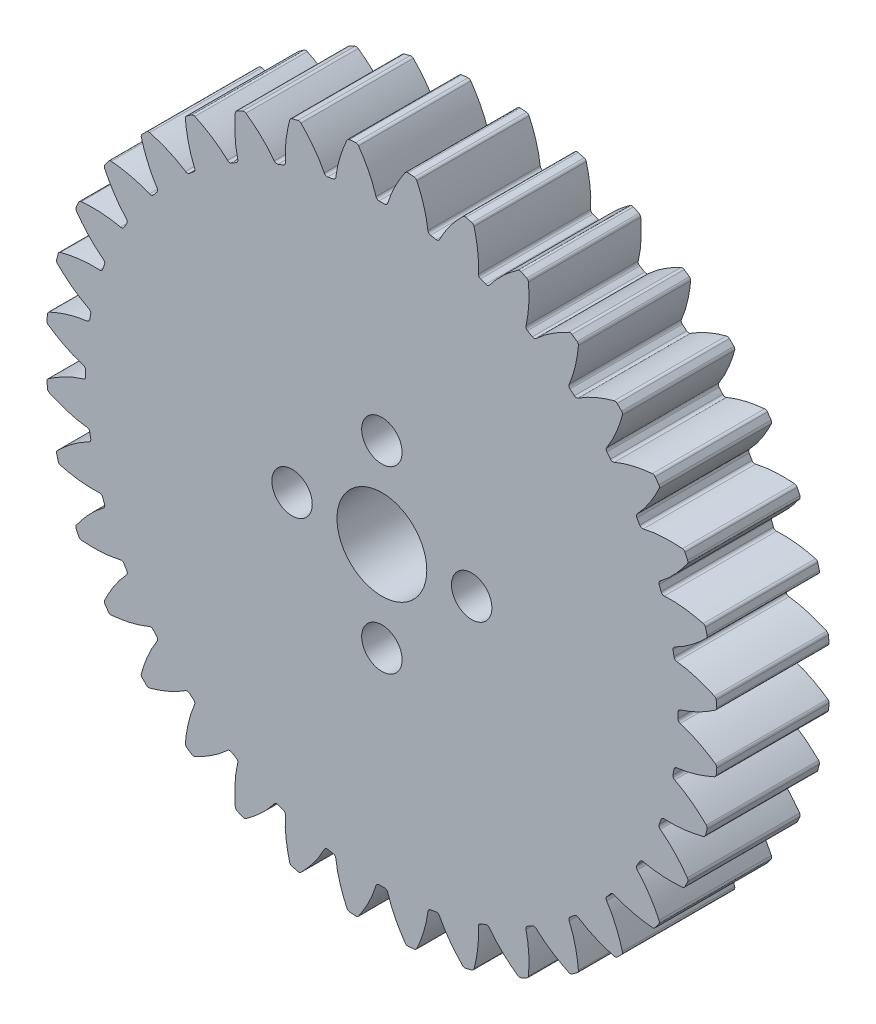
from build123d import *

# Parameters (mm, degrees)
SKETCH1_R                                = 19
BOSS_EXTRUDE1_DEPTH                      = 6.35
CUT_EXTRUDE_DCGTBC_DEPTH                 = 7.35
FILLET_TIP_DCGTBC_R                      = 0.177827283
CIRPATTERN_DCGTBC_COUNT                  = 36
FILLET_TIP_DCGTBC_OF_CIRPATTERN_DCGTBC_R = 0.177827283
SKETCH4_R                                = 2.54
CUT_EXTRUDE2_DEPTH                       = 7.3500001
SKETCH5_R                                = 1.143
CUT_EXTRUDE7_DEPTH                       = 12.7


with BuildPart() as part:
    # Sketch1 → Boss-Extrude1 (new body)
    with BuildSketch(Plane.XY):
        Circle(SKETCH1_R)
    extrude(amount=BOSS_EXTRUDE1_DEPTH)

    # DCGTBC → Cut-Extrude-DCGTBC (cut, through all)
    with BuildSketch(Plane.XY):
        with BuildLine():
            add(Edge.make_bspline(
                [(0.29704595, 16.747365874), (0.298715281, 16.754000326), (0.305790422, 16.781837292), (0.318741059, 16.830755481), (0.338462236, 16.900540736), (0.363884311, 16.984252564), (0.396683632, 17.085360101), (0.438797846, 17.206173577), (0.492066502, 17.346707309), (0.557243274, 17.505246447), (0.628738854, 17.665836752), (0.703249343, 17.823018377), (0.783288406, 17.980785462), (0.864099114, 18.13268838), (0.95287532, 18.289306313), (1.037284199, 18.433287332), (1.137172939, 18.593224042), (1.219340619, 18.721900199), (1.308631383, 18.853618864), (1.352739478, 18.917546944), (1.375554666, 18.950141144)],
                knots=[0.138286232, 0.138286232, 0.138286232, 0.138286232, 0.138286232, 0.146842496, 0.174208854, 0.201574956, 0.228941013, 0.256307345, 0.307035032, 0.361767352, 0.416499661, 0.471231937, 0.525964282, 0.580696616, 0.635428982, 0.690161387, 0.744893688, 0.799626082, 0.854358407, 0.909090915, 0.909090915, 0.909090915, 0.909090915, 0.909090915], degree=4))
            ThreePointArc((1.375554666, 18.950141144), (0, 19), (-1.375554666, 18.950141144))
            add(Edge.make_bspline(
                [(-0.29704595, 16.747365874), (-0.298715281, 16.754000326), (-0.305790422, 16.781837292), (-0.318741059, 16.830755481), (-0.338462236, 16.900540736), (-0.363884311, 16.984252564), (-0.396683632, 17.085360101), (-0.438797846, 17.206173577), (-0.492066502, 17.346707309), (-0.557243274, 17.505246447), (-0.628738854, 17.665836752), (-0.703249343, 17.823018377), (-0.783288406, 17.980785462), (-0.864099114, 18.13268838), (-0.95287532, 18.289306313), (-1.037284199, 18.433287332), (-1.137172939, 18.593224042), (-1.219340619, 18.721900199), (-1.308631383, 18.853618864), (-1.352739478, 18.917546944), (-1.375554666, 18.950141144)],
                knots=[0.138286232, 0.138286232, 0.138286232, 0.138286232, 0.138286232, 0.146842496, 0.174208854, 0.201574956, 0.228941013, 0.256307345, 0.307035032, 0.361767352, 0.416499661, 0.471231937, 0.525964282, 0.580696616, 0.635428982, 0.690161387, 0.744893688, 0.799626082, 0.854358407, 0.909090915, 0.909090915, 0.909090915, 0.909090915, 0.909090915], degree=4))
            ThreePointArc((-0.29704595, 16.747365874), (0, 16.75), (0.29704595, 16.747365874))
        make_face()
    cut_extrude_dcgtbc = extrude(amount=CUT_EXTRUDE_DCGTBC_DEPTH, mode=Mode.SUBTRACT)

    # Fillet-Tip-DCGTBC
    fillet_tip_dcgtbc_edges = [part.edges().sort_by_distance(p)[0] for p in [
        (1.375554666, 18.950141144, 3.175),
        (-1.375554666, 18.950141144, 3.175),
        (0.29704595, 16.747365874, 3.175),
        (-0.29704595, 16.747365874, 3.175),
    ]]
    fillet(fillet_tip_dcgtbc_edges, radius=FILLET_TIP_DCGTBC_R)

    # CirPattern-DCGTBC: Cut-Extrude-DCGTBC ×36 about axis
    cirpattern_dcgtbc_axis = Axis((0, 0, 6.35), (0, 0, 1))
    for i in range(1, CIRPATTERN_DCGTBC_COUNT):
        add(cut_extrude_dcgtbc.rotate(cirpattern_dcgtbc_axis, i * 360 / CIRPATTERN_DCGTBC_COUNT), mode=Mode.SUBTRACT)

    # Fillet-Tip-DCGTBC of CirPattern-DCGTBC
    fillet_tip_dcgtbc_of_cirpattern_dcgtbc_edges = [part.edges().sort_by_distance(p)[0] for p in [
        (-1.936000577, 18.90110848, 3.175),
        (-4.645314376, 18.423383358, 3.175),
        (-2.61561641, 16.544517243, 3.175),
        (-3.20068272, 16.441354267, 3.175),
        (-5.188731421, 18.277775199, 3.175),
        (-7.773928559, 17.336840391, 3.175),
        (-5.448804589, 15.838971828, 3.175),
        (-6.007068364, 15.63578043, 3.175),
        (-8.283805287, 17.099080969, 3.175),
        (-10.666335857, 15.723526303, 3.175),
        (-8.116433598, 14.652167268, 3.175),
        (-8.630932276, 14.355121318, 3.175),
        (-11.127179921, 15.400839815, 3.175),
        (-13.234651937, 13.632460824, 3.175),
        (-10.537448879, 13.020164021, 3.175),
        (-10.992549678, 12.638289108, 3.175),
        (-13.632460824, 13.234651937, 3.175),
        (-15.400839815, 11.127179921, 3.175),
        (-12.638289108, 10.992549678, 3.175),
        (-13.020164021, 10.537448879, 3.175),
        (-15.723526303, 10.666335857, 3.175),
        (-17.099080969, 8.283805287, 3.175),
        (-14.355121318, 8.630932276, 3.175),
        (-14.652167268, 8.116433598, 3.175),
        (-17.336840391, 7.773928559, 3.175),
        (-18.277775199, 5.188731421, 3.175),
        (-15.63578043, 6.007068364, 3.175),
        (-15.838971828, 5.448804589, 3.175),
        (-18.423383358, 4.645314376, 3.175),
        (-18.90110848, 1.936000577, 3.175),
        (-16.441354267, 3.20068272, 3.175),
        (-16.544517243, 2.61561641, 3.175),
        (-18.950141144, 1.375554666, 3.175),
        (-18.950141144, -1.375554666, 3.175),
        (-16.747365874, 0.29704595, 3.175),
        (-16.747365874, -0.29704595, 3.175),
        (-18.90110848, -1.936000577, 3.175),
        (-18.423383358, -4.645314376, 3.175),
        (-16.544517243, -2.61561641, 3.175),
        (-16.441354267, -3.20068272, 3.175),
        (-18.277775199, -5.188731421, 3.175),
        (-17.336840391, -7.773928559, 3.175),
        (-15.838971828, -5.448804589, 3.175),
        (-15.63578043, -6.007068364, 3.175),
        (-17.099080969, -8.283805287, 3.175),
        (-15.723526303, -10.666335857, 3.175),
        (-14.652167268, -8.116433598, 3.175),
        (-14.355121318, -8.630932276, 3.175),
        (-15.400839815, -11.127179921, 3.175),
        (-13.632460824, -13.234651937, 3.175),
        (-13.020164021, -10.537448879, 3.175),
        (-12.638289108, -10.992549678, 3.175),
        (-13.234651937, -13.632460824, 3.175),
        (-11.127179921, -15.400839815, 3.175),
        (-10.992549678, -12.638289108, 3.175),
        (-10.537448879, -13.020164021, 3.175),
        (-10.666335857, -15.723526303, 3.175),
        (-8.283805287, -17.099080969, 3.175),
        (-8.630932276, -14.355121318, 3.175),
        (-8.116433598, -14.652167268, 3.175),
        (-7.773928559, -17.336840391, 3.175),
        (-5.188731421, -18.277775199, 3.175),
        (-6.007068364, -15.63578043, 3.175),
        (-5.448804589, -15.838971828, 3.175),
        (-4.645314376, -18.423383358, 3.175),
        (-1.936000577, -18.90110848, 3.175),
        (-3.20068272, -16.441354267, 3.175),
        (-2.61561641, -16.544517243, 3.175),
        (-1.375554666, -18.950141144, 3.175),
        (1.375554666, -18.950141144, 3.175),
        (-0.29704595, -16.747365874, 3.175),
        (0.29704595, -16.747365874, 3.175),
        (1.936000577, -18.90110848, 3.175),
        (4.645314376, -18.423383358, 3.175),
        (2.61561641, -16.544517243, 3.175),
        (3.20068272, -16.441354267, 3.175),
        (5.188731421, -18.277775199, 3.175),
        (7.773928559, -17.336840391, 3.175),
        (5.448804589, -15.838971828, 3.175),
        (6.007068364, -15.63578043, 3.175),
        (8.283805287, -17.099080969, 3.175),
        (10.666335857, -15.723526303, 3.175),
        (8.116433598, -14.652167268, 3.175),
        (8.630932276, -14.355121318, 3.175),
        (11.127179921, -15.400839815, 3.175),
        (13.234651937, -13.632460824, 3.175),
        (10.537448879, -13.020164021, 3.175),
        (10.992549678, -12.638289108, 3.175),
        (13.632460824, -13.234651937, 3.175),
        (15.400839815, -11.127179921, 3.175),
        (12.638289108, -10.992549678, 3.175),
        (13.020164021, -10.537448879, 3.175),
        (15.723526303, -10.666335857, 3.175),
        (17.099080969, -8.283805287, 3.175),
        (14.355121318, -8.630932276, 3.175),
        (14.652167268, -8.116433598, 3.175),
        (17.336840391, -7.773928559, 3.175),
        (18.277775199, -5.188731421, 3.175),
        (15.63578043, -6.007068364, 3.175),
        (15.838971828, -5.448804589, 3.175),
        (18.423383358, -4.645314376, 3.175),
        (18.90110848, -1.936000577, 3.175),
        (16.441354267, -3.20068272, 3.175),
        (16.544517243, -2.61561641, 3.175),
        (18.950141144, -1.375554666, 3.175),
        (18.950141144, 1.375554666, 3.175),
        (16.747365874, -0.29704595, 3.175),
        (16.747365874, 0.29704595, 3.175),
        (18.90110848, 1.936000577, 3.175),
        (18.423383358, 4.645314376, 3.175),
        (16.544517243, 2.61561641, 3.175),
        (16.441354267, 3.20068272, 3.175),
        (18.277775199, 5.188731421, 3.175),
        (17.336840391, 7.773928559, 3.175),
        (15.838971828, 5.448804589, 3.175),
        (15.63578043, 6.007068364, 3.175),
        (17.099080969, 8.283805287, 3.175),
        (15.723526303, 10.666335857, 3.175),
        (14.652167268, 8.116433598, 3.175),
        (14.355121318, 8.630932276, 3.175),
        (15.400839815, 11.127179921, 3.175),
        (13.632460824, 13.234651937, 3.175),
        (13.020164021, 10.537448879, 3.175),
        (12.638289108, 10.992549678, 3.175),
        (13.234651937, 13.632460824, 3.175),
        (11.127179921, 15.400839815, 3.175),
        (10.992549678, 12.638289108, 3.175),
        (10.537448879, 13.020164021, 3.175),
        (10.666335857, 15.723526303, 3.175),
        (8.283805287, 17.099080969, 3.175),
        (8.630932276, 14.355121318, 3.175),
        (8.116433598, 14.652167268, 3.175),
        (7.773928559, 17.336840391, 3.175),
        (5.188731421, 18.277775199, 3.175),
        (6.007068364, 15.63578043, 3.175),
        (5.448804589, 15.838971828, 3.175),
        (4.645314376, 18.423383358, 3.175),
        (1.936000577, 18.90110848, 3.175),
        (3.20068272, 16.441354267, 3.175),
        (2.61561641, 16.544517243, 3.175),
    ]]
    fillet(fillet_tip_dcgtbc_of_cirpattern_dcgtbc_edges, radius=FILLET_TIP_DCGTBC_OF_CIRPATTERN_DCGTBC_R)

    # Sketch4 → Cut-Extrude2 (cut, through all)
    with BuildSketch(Plane.XY.offset(6.35)):
        Circle(SKETCH4_R)
    extrude(amount=-CUT_EXTRUDE2_DEPTH, mode=Mode.SUBTRACT)

    # Sketch5 → Cut-Extrude7 (cut)
    with BuildSketch(Plane.XY):
        with Locations((5.08, 0)):
            Circle(SKETCH5_R)
        with Locations((0, 5.08)):
            Circle(SKETCH5_R)
        with Locations((-5.08, 0)):
            Circle(SKETCH5_R)
        with Locations((0, -5.08)):
            Circle(SKETCH5_R)
    extrude(amount=CUT_EXTRUDE7_DEPTH, mode=Mode.SUBTRACT)


solid = part.part
